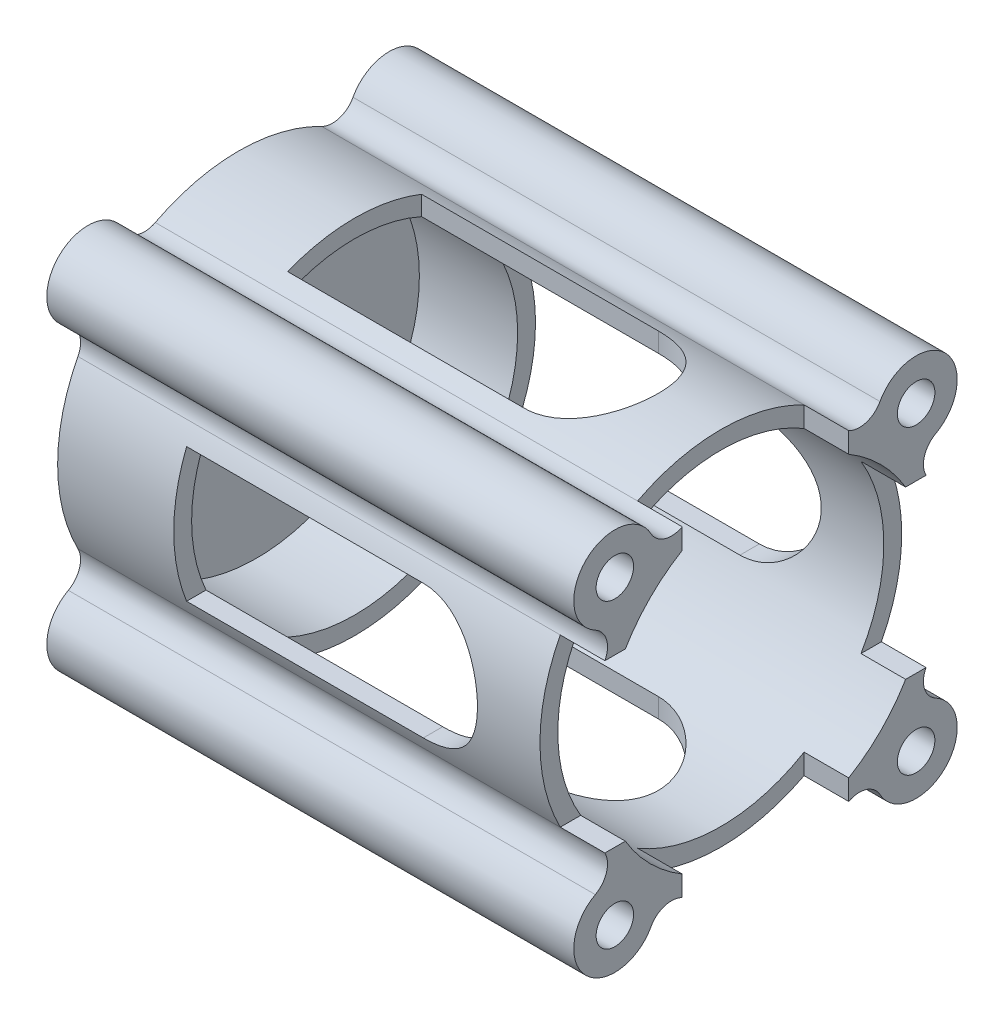
from build123d import *

# Parameters (mm, degrees)
SKETCH_1_R               = 20.25
EXTRUDE_1_DEPTH          = 2
SKETCH_2_R               = 3.5
CUT_EXTRUDE_1_DEPTH      = 3
SKETCH_3_R               = 20.25
SKETCH_3_R_2             = 10.25
EXTRUDE_2_DEPTH          = 4.1
SKETCH_5_R               = 20.25
SKETCH_5_R_2             = 16.25
EXTRUDE_3_DEPTH          = 5.4
SKETCH_6_R               = 20.25
SKETCH_6_R_2             = 18.25
EXTRUDE_4_DEPTH          = 47.5
SKETCH_7_R               = 1.5
CUT_EXTRUDE_2_DEPTH      = 60
PATTERN_CIRCULAR_1_COUNT = 4
FILLET_1_R               = 0.5
SKETCH_9_R               = 4.6
SKETCH_9_R_2             = 2.1
EXTRUDE_6_DEPTH          = 59
EXTRUDE_7_DEPTH          = 59
PATTERN_CIRCULAR_3_COUNT = 4
CUT_EXTRUDE_3_DEPTH      = 22.464496731
PATTERN_CIRCULAR_4_COUNT = 2
PATTERN_CIRCULAR_4_ANGLE = 270
SKETCH_22_R              = 18.25
CUT_EXTRUDE_9_DEPTH      = 20
SKETCH_23_W              = 5
SKETCH_23_H              = 18.640041254
CUT_EXTRUDE_10_DEPTH     = 43.928993463
PATTERN_CIRCULAR_5_COUNT = 2
PATTERN_CIRCULAR_5_ANGLE = 270


with BuildPart() as part:
    # Эскиз1 → Бобышка-Вытянуть1 (new body)
    with BuildSketch(Plane(origin=(0, 0, 0), x_dir=(0, 0, -1), z_dir=(1, 0, 0))):
        Circle(SKETCH_1_R)
    extrude(amount=EXTRUDE_1_DEPTH)

    # Эскиз2 → Вырез-Вытянуть1 (cut, through all)
    with BuildSketch(Plane.ZY):
        Circle(SKETCH_2_R)
    extrude(amount=-CUT_EXTRUDE_1_DEPTH, mode=Mode.SUBTRACT)

    # Эскиз3 → Бобышка-Вытянуть2 (add)
    with BuildSketch(Plane(origin=(2, 0, 0), x_dir=(0, 0, -1), z_dir=(1, 0, 0))):
        Circle(SKETCH_3_R)
        Circle(SKETCH_3_R_2, mode=Mode.SUBTRACT)
    extrude(amount=EXTRUDE_2_DEPTH)

    # Эскиз5 → Бобышка-Вытянуть3 (add)
    with BuildSketch(Plane(origin=(6.1, 0, 0), x_dir=(0, 0, -1), z_dir=(1, 0, 0))):
        Circle(SKETCH_5_R)
        Circle(SKETCH_5_R_2, mode=Mode.SUBTRACT)
    extrude(amount=EXTRUDE_3_DEPTH)

    # Эскиз6 → Бобышка-Вытянуть4 (add)
    with BuildSketch(Plane(origin=(11.5, 0, 0), x_dir=(0, 0, -1), z_dir=(1, 0, 0))):
        Circle(SKETCH_6_R)
        Circle(SKETCH_6_R_2, mode=Mode.SUBTRACT)
    extrude(amount=EXTRUDE_4_DEPTH)

    # Эскиз7 → Вырез-Вытянуть2 (cut, through all)
    with BuildSketch(Plane.ZY):
        with Locations((-9.192388155, 9.192388155)):
            Circle(SKETCH_7_R)
    cut_extrude_2 = extrude(amount=-CUT_EXTRUDE_2_DEPTH, mode=Mode.SUBTRACT)

    # Круговой массив1: Вырез-Вытянуть2 ×4 about axis
    pattern_circular_1_axis = Axis((0, 0, 0), (1, 0, 0))
    for i in range(1, PATTERN_CIRCULAR_1_COUNT):
        add(cut_extrude_2.rotate(pattern_circular_1_axis, i * 360 / PATTERN_CIRCULAR_1_COUNT), mode=Mode.SUBTRACT)

    # Скругление1
    fillet_1_edges = [part.edges().sort_by_distance(p)[0] for p in [
        (2, 0, 10.25),
        (6.1, 0, 10.25),
        (6.1, 0, 16.25),
        (11.5, 0, 16.25),
        (11.5, 0, 18.25),
    ]]
    fillet(fillet_1_edges, radius=FILLET_1_R)

    # Эскиз9 → Бобышка-Вытянуть6 (add)
    with BuildSketch(Plane.ZY):
        with Locations((-16.864496731, 16.864496731)):
            Circle(SKETCH_9_R)
        with Locations((-16.864496731, 16.864496731)):
            Circle(SKETCH_9_R_2, mode=Mode.SUBTRACT)
    extrude_6 = extrude(amount=-EXTRUDE_6_DEPTH)

    # Эскиз10 → Бобышка-Вытянуть7 (add)
    with BuildSketch(Plane.ZY):
        with BuildLine():
            ThreePointArc((-9.320020627, 17.977756131), (-11.289373131, 17.800047957), (-12.818708454, 19.053468456))
            ThreePointArc((-12.818708454, 19.053468456), (-12.323239372, 17.597287013), (-12.335539952, 16.059170405))
            ThreePointArc((-12.335539952, 16.059170405), (-10.870191755, 17.085123096), (-9.320020627, 17.977756131))
        make_face()
        with BuildLine():
            ThreePointArc((-16.059170405, 12.335539952), (-17.597287013, 12.323239372), (-19.053468456, 12.818708454))
            ThreePointArc((-19.053468456, 12.818708454), (-17.800047957, 11.289373131), (-17.977756131, 9.320020627))
            ThreePointArc((-17.977756131, 9.320020627), (-17.085123096, 10.870191755), (-16.059170405, 12.335539952))
        make_face()
    extrude_7 = extrude(amount=-EXTRUDE_7_DEPTH)

    # Круговой массив3: Бобышка-Вытянуть6, Бобышка-Вытянуть7 ×4 about axis
    pattern_circular_3_axis = Axis((0, 0, 0), (1, 0, 0))
    for i in range(1, PATTERN_CIRCULAR_3_COUNT):
        add(extrude_6.rotate(pattern_circular_3_axis, i * 360 / PATTERN_CIRCULAR_3_COUNT))
        add(extrude_7.rotate(pattern_circular_3_axis, i * 360 / PATTERN_CIRCULAR_3_COUNT))

    # Эскиз11 → Вырез-Вытянуть3 (cut, symmetric)
    with BuildSketch(Plane(origin=(0, 0, 0), x_dir=(1, 0, 0), z_dir=(0, 1, 0))):
        with BuildLine():
            Line((13, 7.5), (39.5, 7.5))
            ThreePointArc((39.5, 7.5), (47, 0), (39.5, -7.5))
            Line((39.5, -7.5), (13, -7.5))
            Line((13, -7.5), (13, 7.5))
        make_face()
    cut_extrude_3 = extrude(amount=CUT_EXTRUDE_3_DEPTH, both=True, mode=Mode.SUBTRACT)

    # Круговой массив4: Вырез-Вытянуть3 ×2 about axis
    pattern_circular_4_axis = Axis((2, 0, 0), (-1, 0, 0))
    for i in range(1, PATTERN_CIRCULAR_4_COUNT):
        add(cut_extrude_3.rotate(pattern_circular_4_axis, i * PATTERN_CIRCULAR_4_ANGLE / (PATTERN_CIRCULAR_4_COUNT - 1)), mode=Mode.SUBTRACT)

    # Эскиз22 → Вырез-Вытянуть9 (cut)
    with BuildSketch(Plane(origin=(2, 0, 0), x_dir=(0, 0, -1), z_dir=(1, 0, 0))):
        Circle(SKETCH_22_R)
    extrude(amount=CUT_EXTRUDE_9_DEPTH, mode=Mode.SUBTRACT)

    # Эскиз23 → Вырез-Вытянуть10 (cut, through all)
    with BuildSketch(Plane(origin=(0, -21.464496731, 0), x_dir=(-1, 0, 0), z_dir=(0, -1, 0))):
        with Locations((-56.5, 0)):
            Rectangle(SKETCH_23_W, SKETCH_23_H)
    cut_extrude_10 = extrude(amount=-CUT_EXTRUDE_10_DEPTH, mode=Mode.SUBTRACT)

    # Круговой массив5: Вырез-Вытянуть10 ×2 about axis
    pattern_circular_5_axis = Axis((2, 0, 0), (-1, 0, 0))
    for i in range(1, PATTERN_CIRCULAR_5_COUNT):
        add(cut_extrude_10.rotate(pattern_circular_5_axis, i * PATTERN_CIRCULAR_5_ANGLE / (PATTERN_CIRCULAR_5_COUNT - 1)), mode=Mode.SUBTRACT)


solid = part.part
